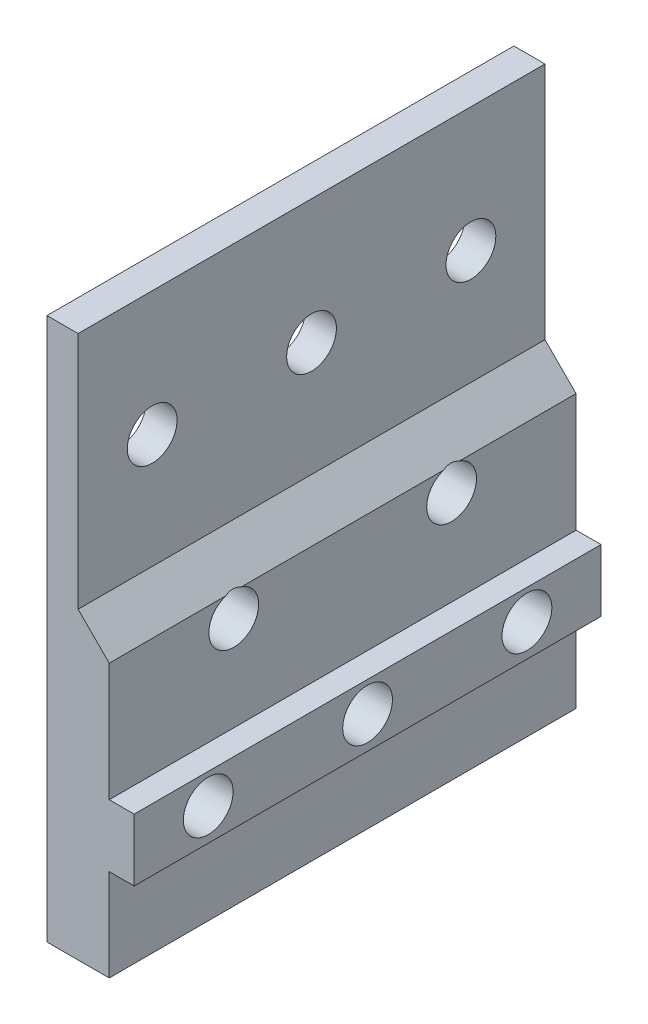
from build123d import *

# Parameters (mm, degrees)
BOSS_EXTRUDE1_DEPTH = 47.625
SKETCH2_R           = 2.54
CUT_EXTRUDE1_DEPTH  = 9.89


with BuildPart() as part:
    # Sketch1 → Boss-Extrude1 (new body)
    with BuildSketch(Plane.XY):
        Polygon((0, 0), (0, 55.3466), (3.175, 55.3466), (3.175, 30.988), (6.35, 27.813), (6.35, 15.748), (8.89, 15.748), (8.89, 9.398), (6.35, 9.398), (6.35, 0), align=None)
    extrude(amount=BOSS_EXTRUDE1_DEPTH)

    # Sketch2 → Cut-Extrude1 (cut, through all)
    with BuildSketch(Plane.ZY):
        with Locations((40.0685, 12.7)):
            Circle(SKETCH2_R)
        with Locations((7.5565, 12.7)):
            Circle(SKETCH2_R)
        with Locations((12.7, 25.4)):
            Circle(SKETCH2_R)
        with Locations((34.925, 25.4)):
            Circle(SKETCH2_R)
        with Locations((7.5565, 42.6466)):
            Circle(SKETCH2_R)
        with Locations((40.0685, 42.6466)):
            Circle(SKETCH2_R)
        with Locations((23.8125, 12.7)):
            Circle(SKETCH2_R)
        with Locations((23.8125, 42.6466)):
            Circle(SKETCH2_R)
    extrude(amount=-CUT_EXTRUDE1_DEPTH, mode=Mode.SUBTRACT)


solid = part.part
